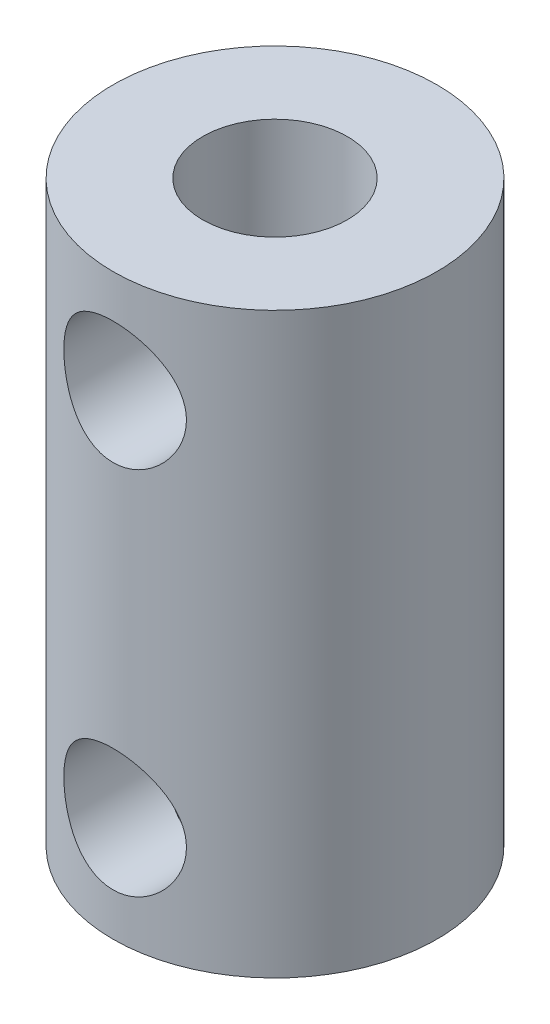
from build123d import *

# Parameters (mm, degrees)
SKETCH1_R                       = 5.334
BOSS_EXTRUDE1_DEPTH             = 19.05
F_3_16_0_1875_DOWEL_HOLE2_D     = 4.7625
F_3_16_0_1875_DOWEL_HOLE2_DEPTH = 9.525
F_3_16_0_1875_DOWEL_HOLE2_TIP   = 1.430799349
F_5_0MM_DOWEL_HOLE2_D           = 5
F_5_0MM_DOWEL_HOLE2_DEPTH       = 9.525
F_5_0MM_DOWEL_HOLE2_TIP         = 1.502151548
F_10_32_TAPPED_HOLE1_REACH      = 26.836
F_10_32_TAPPED_HOLE1_BORE_R     = 2.0193


with BuildPart() as part:
    # Sketch1 → Boss-Extrude1 (new body)
    with BuildSketch(Plane(origin=(0, 0, 0), x_dir=(1, 0, 0), z_dir=(0, 1, 0))):
        with Locations(Location((0, 0, 0), (0, 0, 90))):
            Circle(SKETCH1_R)
    extrude(amount=BOSS_EXTRUDE1_DEPTH)

    # 3/16 (0.1875) Dowel Hole2
    with Locations(Plane(origin=(0, 19.05, 0), x_dir=(1, 0, 0), z_dir=(0, 1, 0))):
        with Locations((0, 0)):
            Hole(F_3_16_0_1875_DOWEL_HOLE2_D / 2, depth=F_3_16_0_1875_DOWEL_HOLE2_DEPTH)
            with Locations((0, 0, -(F_3_16_0_1875_DOWEL_HOLE2_DEPTH + F_3_16_0_1875_DOWEL_HOLE2_TIP / 2))):  # 118° drill point
                Cone(0, F_3_16_0_1875_DOWEL_HOLE2_D / 2, F_3_16_0_1875_DOWEL_HOLE2_TIP, mode=Mode.SUBTRACT)

    # Ø5.0mm Dowel Hole2
    with Locations(Plane(origin=(0, 0, 0), x_dir=(-1, 0, 0), z_dir=(0, -1, 0))):
        with Locations((0, 0)):
            Hole(F_5_0MM_DOWEL_HOLE2_D / 2, depth=F_5_0MM_DOWEL_HOLE2_DEPTH)
            with Locations((0, 0, -(F_5_0MM_DOWEL_HOLE2_DEPTH + F_5_0MM_DOWEL_HOLE2_TIP / 2))):  # 118° drill point
                Cone(0, F_5_0MM_DOWEL_HOLE2_D / 2, F_5_0MM_DOWEL_HOLE2_TIP, mode=Mode.SUBTRACT)

    # #10-32 Tapped Hole1 bore → #10-32 Tapped Hole1 (cut, up to next)
    with BuildSketch(Plane.XY.offset(9.681668378), mode=Mode.PRIVATE) as f_10_32_tapped_hole1_sk1:
        with Locations((0, 15.621)):
            Circle(F_10_32_TAPPED_HOLE1_BORE_R)
    f_10_32_tapped_hole1_tool1 = extrude(f_10_32_tapped_hole1_sk1.sketch, amount=-F_10_32_TAPPED_HOLE1_REACH, mode=Mode.PRIVATE) & part.part
    # #10-32 Tapped Hole1 bore → #10-32 Tapped Hole1 (cut, up to next)
    with BuildSketch(Plane.XY.offset(9.681668378), mode=Mode.PRIVATE) as f_10_32_tapped_hole1_sk2:
        with Locations((0, 3.429)):
            Circle(F_10_32_TAPPED_HOLE1_BORE_R)
    f_10_32_tapped_hole1_tool2 = extrude(f_10_32_tapped_hole1_sk2.sketch, amount=-F_10_32_TAPPED_HOLE1_REACH, mode=Mode.PRIVATE) & part.part
    add(f_10_32_tapped_hole1_tool1.solids().sort_by_distance((0, 15.621, 9.681668))[0], mode=Mode.SUBTRACT)
    add(f_10_32_tapped_hole1_tool2.solids().sort_by_distance((0, 3.429, 9.681668))[0], mode=Mode.SUBTRACT)


solid = part.part
